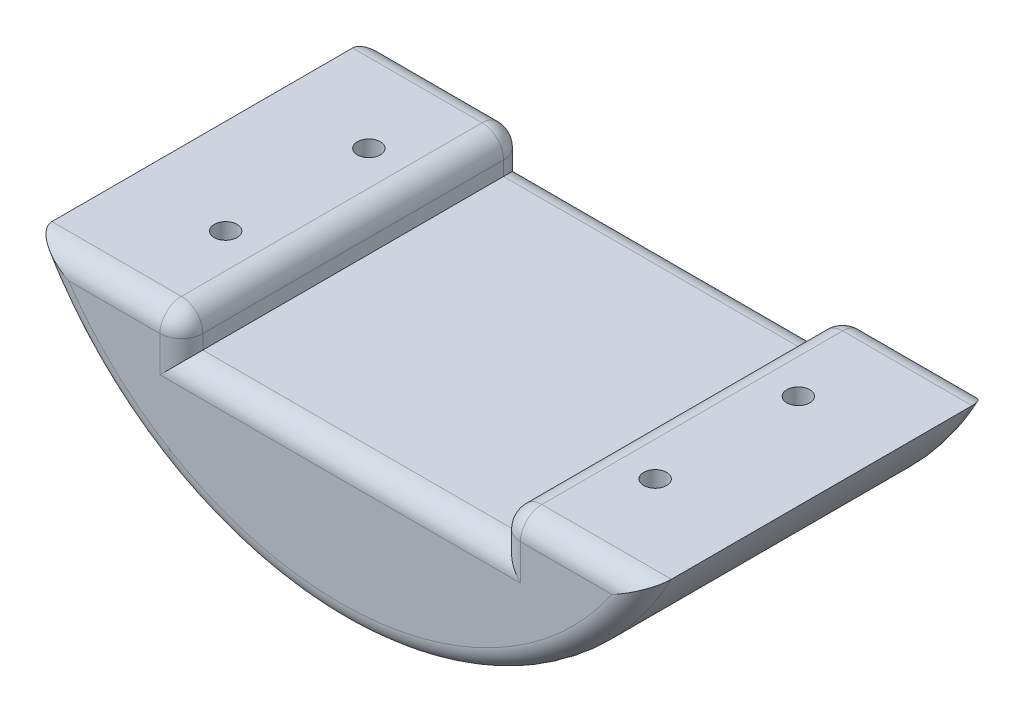
from build123d import *

# Parameters (mm, degrees)
SKETCH1_W           = 44.362146026
SKETCH1_H           = 10
BOSS_EXTRUDE1_DEPTH = 48
SKETCH2_R           = 1.6
CUT_EXTRUDE1_DEPTH  = 27
CUT_EXTRUDE2_START  = -17.925297
SKETCH3_R           = 3.05
CUT_EXTRUDE2_DEPTH  = 12.925297
FILLET1_R           = 3


with BuildPart() as part:
    # Sketch1 → Boss-Extrude1 (new body)
    with BuildSketch(Plane.XY):
        with BuildLine():
            Line((22.181073013, -38), (-22.181073013, -38))
            ThreePointArc((-22.181073013, -38), (0, -44), (22.181073013, -38))
        make_face()
        with BuildLine():
            Line((-37.509998667, -23), (-43.266615306, -23))
            ThreePointArc((-43.266615306, -23), (0, -49), (43.266615306, -23))
            Line((43.266615306, -23), (37.509998667, -23))
            ThreePointArc((37.509998667, -23), (35.812927639, -25.562359318), (33.941125497, -28))
            ThreePointArc((33.941125497, -28), (28.503075122, -33.519765939), (22.181073013, -38))
            ThreePointArc((22.181073013, -38), (0, -44), (-22.181073013, -38))
            ThreePointArc((-22.181073013, -38), (-28.503075122, -33.519765939), (-33.941125497, -28))
            ThreePointArc((-33.941125497, -28), (-35.812927639, -25.562359318), (-37.509998667, -23))
        make_face()
        with BuildLine():
            Line((-29.953929645, -23), (-37.509998667, -23))
            ThreePointArc((-37.509998667, -23), (-35.812927639, -25.562359318), (-33.941125497, -28))
            Line((-33.941125497, -28), (-22.181073013, -28))
            Line((-22.181073013, -28), (-22.181073013, -23))
            Line((-22.181073013, -23), (-29.953929645, -23))
        make_face()
        with BuildLine():
            Line((-22.181073013, -28), (-33.941125497, -28))
            ThreePointArc((-33.941125497, -28), (-28.503075122, -33.519765939), (-22.181073013, -38))
            Line((-22.181073013, -38), (-22.181073013, -28))
        make_face()
        with BuildLine():
            ThreePointArc((33.941125497, -28), (35.812927639, -25.562359318), (37.509998667, -23))
            Line((37.509998667, -23), (22.181073013, -23))
            Line((22.181073013, -23), (22.181073013, -28))
            Line((22.181073013, -28), (33.941125497, -28))
        make_face()
        with BuildLine():
            ThreePointArc((22.181073013, -38), (28.503075122, -33.519765939), (33.941125497, -28))
            Line((33.941125497, -28), (22.181073013, -28))
            Line((22.181073013, -28), (22.181073013, -38))
        make_face()
        with Locations((0, -33)):
            Rectangle(SKETCH1_W, SKETCH1_H)
    extrude(amount=BOSS_EXTRUDE1_DEPTH)

    # Sketch2 → Cut-Extrude1 (cut, through all)
    with BuildSketch(Plane(origin=(0, -23, 0), x_dir=(1, 0, 0), z_dir=(0, 1, 0))):
        with Locations((-29.996615306, -14)):
            Circle(SKETCH2_R)
        with Locations((-29.996615306, -34)):
            Circle(SKETCH2_R)
    cut_extrude1 = extrude(amount=-CUT_EXTRUDE1_DEPTH, mode=Mode.SUBTRACT)

    # Sketch3 → Cut-Extrude2 (cut)
    with BuildSketch(Plane(origin=(0, -23, 0), x_dir=(1, 0, 0), z_dir=(0, 1, 0)).offset(CUT_EXTRUDE2_START)):
        with Locations((-29.996615306, -14)):
            Circle(SKETCH3_R)
        with Locations((-29.996615306, -34)):
            Circle(SKETCH3_R)
    cut_extrude2 = extrude(amount=CUT_EXTRUDE2_DEPTH, mode=Mode.SUBTRACT)

    # Mirror1: Cut-Extrude1, Cut-Extrude2 across plane
    add(cut_extrude1.mirror(Plane(origin=(0, 0, 0), x_dir=(0, 0, 1), z_dir=(1, 0, 0))), mode=Mode.SUBTRACT)
    add(cut_extrude2.mirror(Plane(origin=(0, 0, 0), x_dir=(0, 0, 1), z_dir=(1, 0, 0))), mode=Mode.SUBTRACT)

    # Fillet1
    fillet1_edges = [part.edges().sort_by_distance(p)[0] for p in [
        (-22.181073013, -25.5, 48),
        (-22.181073013, -25.5, 0),
        (0, -28, 0),
        (22.181073013, -23, 24),
        (-22.181073013, -23, 24),
        (-32.723844159, -23, 48),
        (0, -49, 48),
        (32.723844159, -23, 48),
        (22.181073013, -25.5, 48),
        (0, -28, 48),
        (22.181073013, -25.5, 0),
        (32.723844159, -23, 0),
        (0, -49, 0),
        (-32.723844159, -23, 0),
    ]]
    fillet(fillet1_edges, radius=FILLET1_R)


solid = part.part
